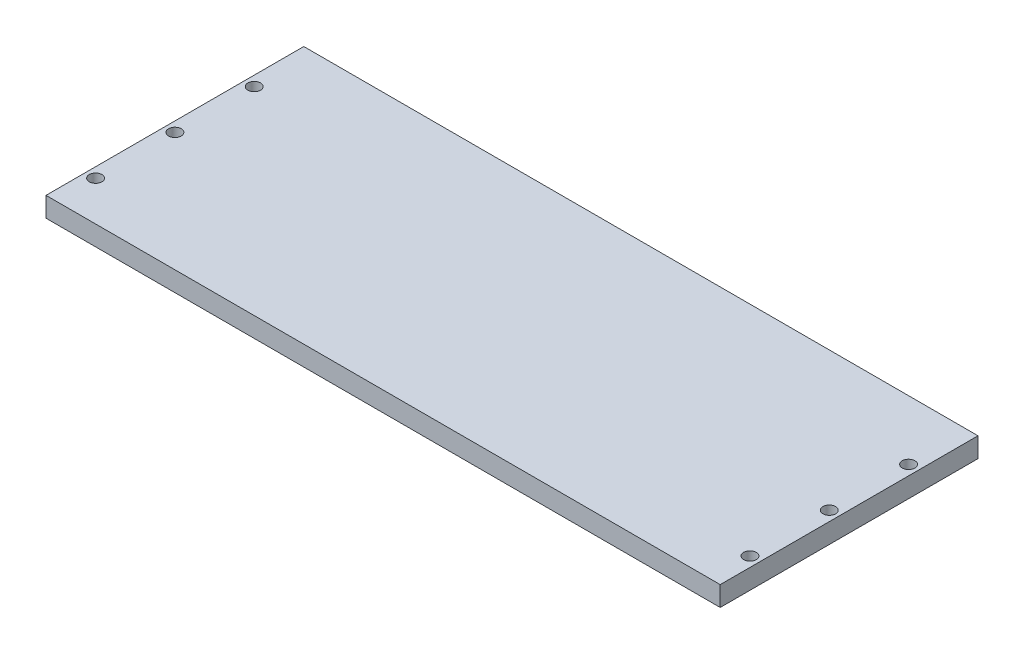
from build123d import *

# Parameters (mm, degrees)
SKETCH1_W           = 170
SKETCH1_H           = 65
SKETCH1_R           = 1.6
BOSS_EXTRUDE1_DEPTH = 5


with BuildPart() as part:
    # Sketch1 → Boss-Extrude1 (new body)
    with BuildSketch(Plane(origin=(0, 0, 0), x_dir=(1, 0, 0), z_dir=(0, 1, 0))):
        Rectangle(SKETCH1_W, SKETCH1_H)
        with Locations((-82.5, 17.5)):
            Circle(SKETCH1_R, mode=Mode.SUBTRACT)
        with Locations((-82.5, -2.5)):
            Circle(SKETCH1_R, mode=Mode.SUBTRACT)
        with Locations((-82.5, -22.5)):
            Circle(SKETCH1_R, mode=Mode.SUBTRACT)
        with Locations((82.5, -22.5)):
            Circle(SKETCH1_R, mode=Mode.SUBTRACT)
        with Locations((82.5, -2.5)):
            Circle(SKETCH1_R, mode=Mode.SUBTRACT)
        with Locations((82.5, 17.5)):
            Circle(SKETCH1_R, mode=Mode.SUBTRACT)
    extrude(amount=BOSS_EXTRUDE1_DEPTH)


solid = part.part
